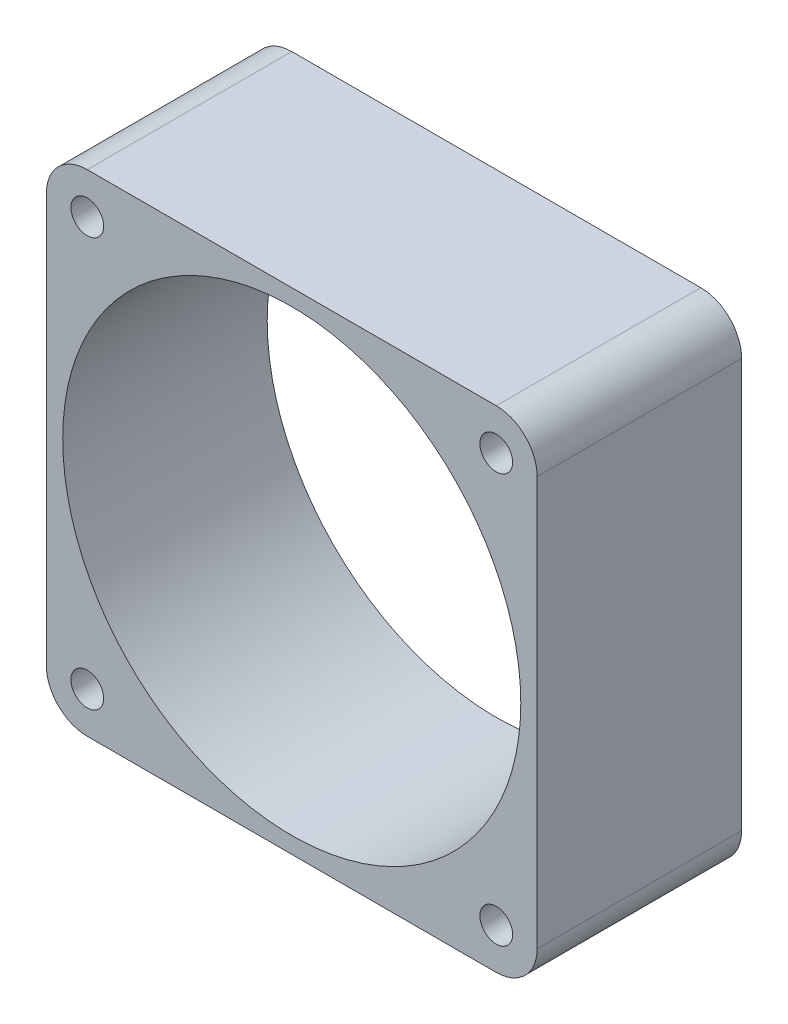
from build123d import *

# Parameters (mm, degrees)
ESQUISSE1_W             = 60
ESQUISSE1_H             = 60
BOSS_EXTRU_1_DEPTH      = 25
ENL_V_MAT_EXTRU_1_REACH = 90.459
ESQUISSE2_R             = 28
ESQUISSE3_R             = 2
ENL_V_MAT_EXTRU_2_DEPTH = 25
CONG_1_R                = 5


with BuildPart() as part:
    # Esquisse1 → Boss.-Extru.1 (new body)
    with BuildSketch(Plane.XY):
        with Locations((-30, 30)):
            Rectangle(ESQUISSE1_W, ESQUISSE1_H)
    extrude(amount=BOSS_EXTRU_1_DEPTH)

    # Esquisse2 → Enlèv. mat.-Extru.1 (cut, up to next)
    with BuildSketch(Plane(origin=(0, 0, 0), x_dir=(-1, 0, 0), z_dir=(0, 0, -1)), mode=Mode.PRIVATE) as enl_v_mat_extru_1_sk1:
        with Locations((30, 30)):
            Circle(ESQUISSE2_R)
    enl_v_mat_extru_1_tool1 = extrude(enl_v_mat_extru_1_sk1.sketch, amount=-ENL_V_MAT_EXTRU_1_REACH, mode=Mode.PRIVATE) & part.part
    add(enl_v_mat_extru_1_tool1.solids().sort_by_distance((-30, 30, 0))[0], mode=Mode.SUBTRACT)

    # Esquisse3 → Enlèv. mat.-Extru.2 (cut)
    with BuildSketch(Plane(origin=(0, 0, 0), x_dir=(-1, 0, 0), z_dir=(0, 0, -1))):
        with Locations((5, 55)):
            Circle(ESQUISSE3_R)
        with Locations((55, 55)):
            Circle(ESQUISSE3_R)
        with Locations((55, 5)):
            Circle(ESQUISSE3_R)
        with Locations((5, 5)):
            Circle(ESQUISSE3_R)
    extrude(amount=-ENL_V_MAT_EXTRU_2_DEPTH, mode=Mode.SUBTRACT)

    # Congé1
    cong_1_edges = [part.edges().sort_by_distance(p)[0] for p in [
        (0, 0, 12.5),
        (-60, 0, 12.5),
        (-60, 60, 12.5),
        (0, 60, 12.5),
    ]]
    fillet(cong_1_edges, radius=CONG_1_R)


solid = part.part
